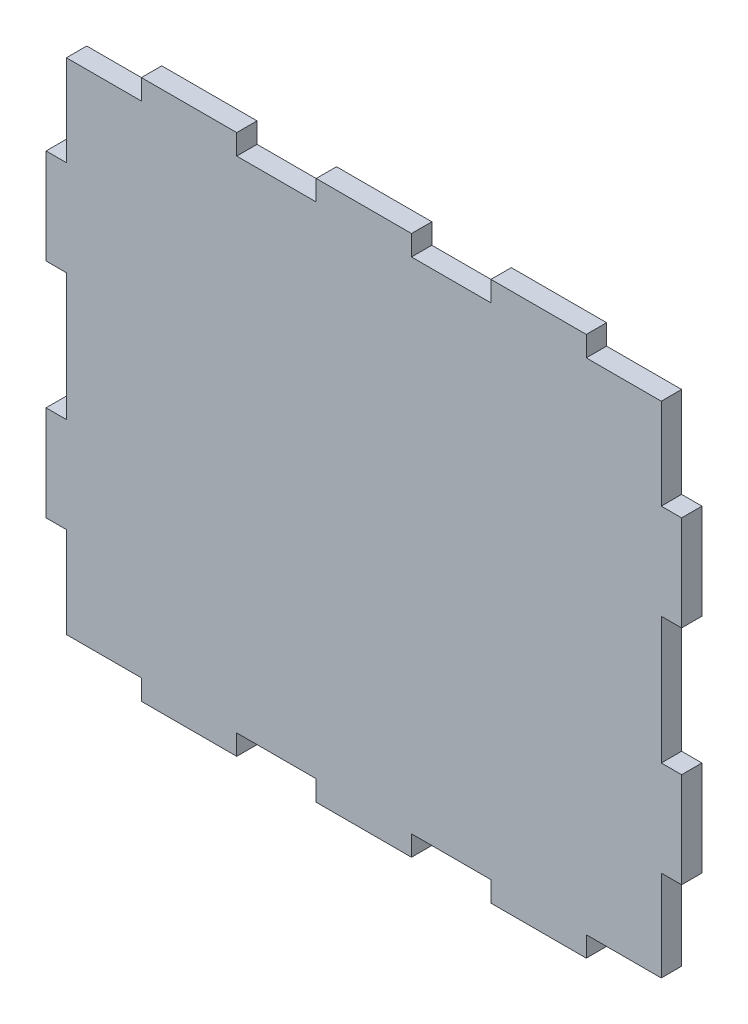
from build123d import *

# Parameters (mm, degrees)
BOSS_EXTRUDE1_DEPTH = 3.2


with BuildPart() as part:
    # Sketch1 → Boss-Extrude1 (new body)
    with BuildSketch(Plane.XY):
        Polygon((-50, 10), (-50, 25), (-46.8, 25), (-46.8, 39.3), (-35, 39.3), (-35, 42.5), (-20, 42.5), (-20, 39.3), (-7.5, 39.3), (-7.5, 42.5), (7.5, 42.5), (7.5, 39.3), (20, 39.3), (20, 42.5), (35, 42.5), (35, 39.3), (46.8, 39.3), (46.8, 25), (50, 25), (50, 10), (46.8, 10), (46.8, -10), (50, -10), (50, -25), (46.8, -25), (46.8, -39.3), (35, -39.3), (35, -42.5), (20, -42.5), (20, -39.3), (7.5, -39.3), (7.5, -42.5), (-7.5, -42.5), (-7.5, -39.3), (-20, -39.3), (-20, -42.5), (-35, -42.5), (-35, -39.3), (-46.8, -39.3), (-46.8, -25), (-50, -25), (-50, -10), (-46.8, -10), (-46.8, 10), align=None)
    extrude(amount=BOSS_EXTRUDE1_DEPTH)


solid = part.part
